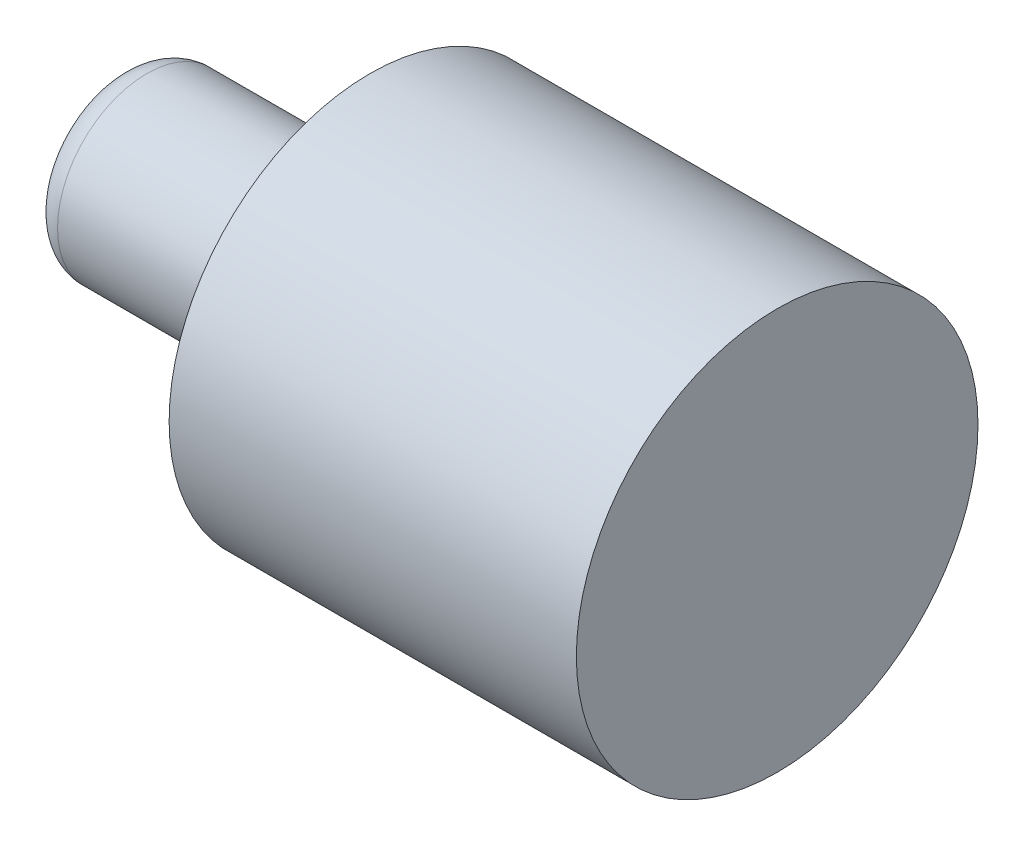
from build123d import *

# Parameters (mm, degrees)
SKETCH3_R           = 16
BOSS_EXTRUDE1_DEPTH = 80
SKETCH4_R           = 36
BOSS_EXTRUDE2_DEPTH = 38
SKETCH6_R           = 36
SKETCH6_R_2         = 16
BOSS_EXTRUDE3_DEPTH = 35
FILLET1_R           = 5


with BuildPart() as part:
    # Sketch3 → Boss-Extrude1 (new body)
    with BuildSketch(Plane(origin=(0, 0, 0), x_dir=(0, 0, -1), z_dir=(1, 0, 0))):
        Circle(SKETCH3_R)
    extrude(amount=BOSS_EXTRUDE1_DEPTH)

    # Sketch4 → Boss-Extrude2 (add)
    with BuildSketch(Plane(origin=(80, 0, 0), x_dir=(0, 0, -1), z_dir=(1, 0, 0))):
        Circle(SKETCH4_R)
    extrude(amount=BOSS_EXTRUDE2_DEPTH)

    # Sketch6 → Boss-Extrude3 (add)
    with BuildSketch(Plane.ZY.offset(-80)):
        Circle(SKETCH6_R)
        Circle(SKETCH6_R_2, mode=Mode.SUBTRACT)
    extrude(amount=BOSS_EXTRUDE3_DEPTH)

    # Fillet1
    fillet1_edges = [part.edges().sort_by_distance(p)[0] for p in [
        (45, 0, 16),
        (0, 0, 16),
    ]]
    fillet(fillet1_edges, radius=FILLET1_R)


solid = part.part
